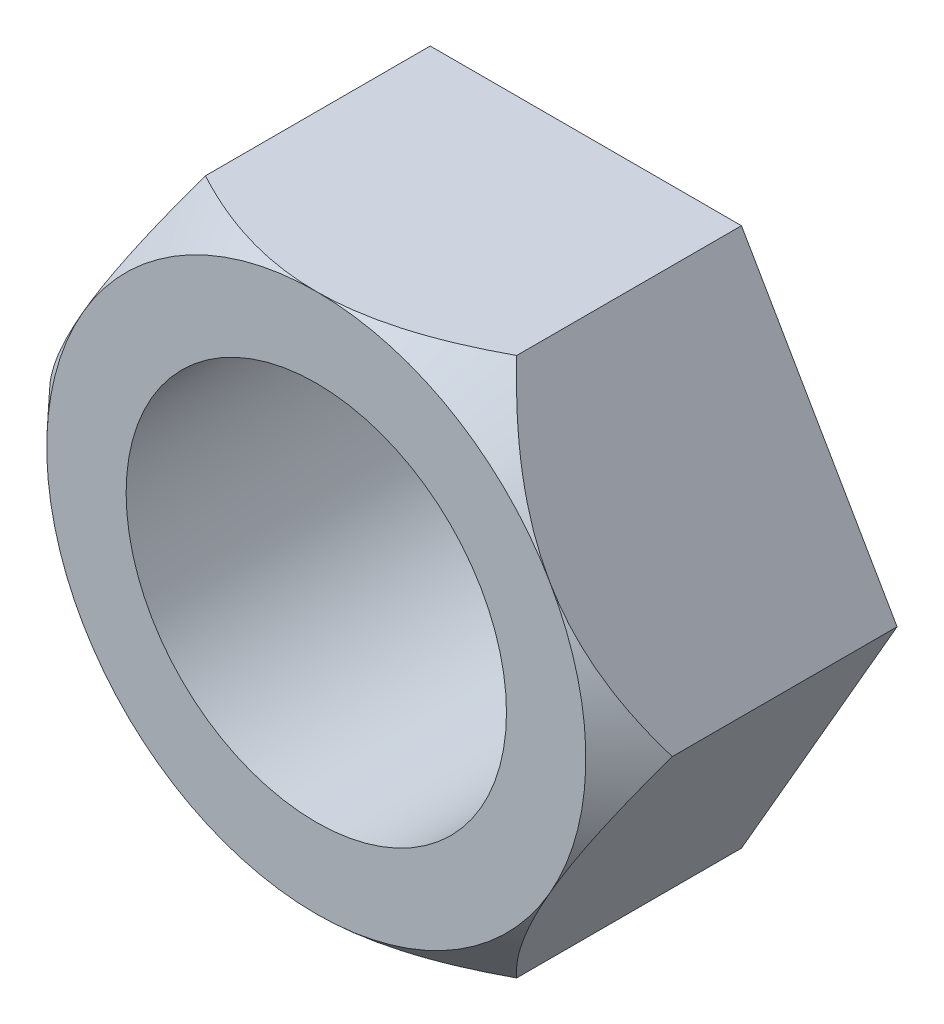
from build123d import *

# Parameters (mm, degrees)
CROQUIS1_R              = 6.35
SALIENTE_EXTRUIR1_DEPTH = 9
CROQUIS2_R              = 17.950209201
CROQUIS2_R_2            = 9
CORTAR_EXTRUIR1_DEPTH   = 9
CORTAR_EXTRUIR1_TAPER   = 43


with BuildPart() as part:
    # Croquis1 → Saliente-Extruir1 (new body)
    with BuildSketch(Plane.XY):
        Polygon((-10.392304845, 0), (-5.196152423, -9), (5.196152423, -9), (10.392304845, 0), (5.196152423, 9), (-5.196152423, 9), align=None)
        Circle(CROQUIS1_R, mode=Mode.SUBTRACT)
    extrude(amount=SALIENTE_EXTRUIR1_DEPTH)

    # Croquis2 → Cortar-Extruir1 (cut)
    with BuildSketch(Plane.XY.offset(9)):
        with Locations((-0.193993057, 0)):
            Circle(CROQUIS2_R)
        Circle(CROQUIS2_R_2, mode=Mode.SUBTRACT)
    extrude(amount=-CORTAR_EXTRUIR1_DEPTH, taper=CORTAR_EXTRUIR1_TAPER, mode=Mode.SUBTRACT)


solid = part.part
